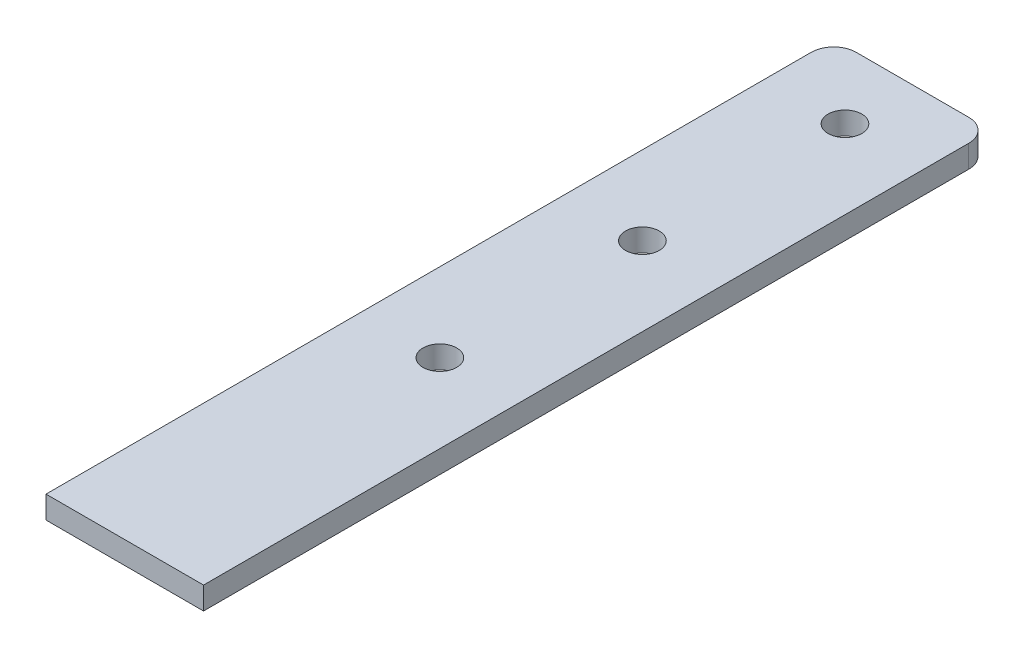
from build123d import *

# Parameters (mm, degrees)
CROQUIS3_R              = 7.5
SALIENTE_EXTRUIR4_DEPTH = 10


with BuildPart() as part:
    # Croquis3 → Saliente-Extruir4 (new body)
    with BuildSketch(Plane(origin=(0, 0, 0), x_dir=(1, 0, 0), z_dir=(0, 1, 0))):
        with BuildLine():
            Line((-35, -175), (35, -175))
            Line((35, -175), (35, 165))
            ThreePointArc((35, 165), (32.071067812, 172.071067812), (25, 175))
            Line((25, 175), (-25, 175))
            ThreePointArc((-25, 175), (-32.071067812, 172.071067812), (-35, 165))
            Line((-35, 165), (-35, -175))
        make_face()
        with Locations((0, 145)):
            Circle(CROQUIS3_R, mode=Mode.SUBTRACT)
        with Locations((0, 55)):
            Circle(CROQUIS3_R, mode=Mode.SUBTRACT)
        with Locations((0, -35)):
            Circle(CROQUIS3_R, mode=Mode.SUBTRACT)
    extrude(amount=SALIENTE_EXTRUIR4_DEPTH)


solid = part.part
